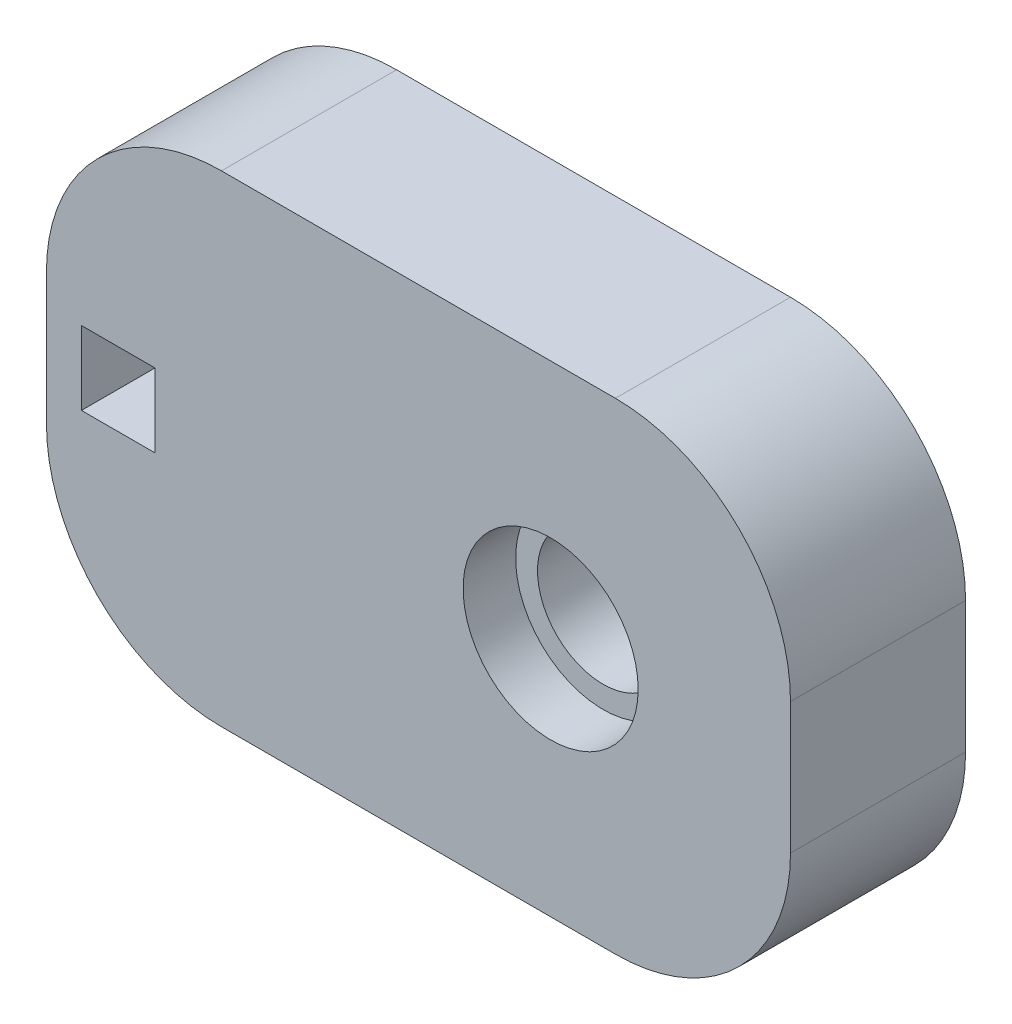
from build123d import *

# Parameters (mm, degrees)
SKETCH1_W           = 42.5
SKETCH1_H           = 27.5
BOSS_EXTRUDE1_DEPTH = 10
SKETCH2_R           = 5
CUT_EXTRUDE1_DEPTH  = 3
SKETCH3_W           = 4.2
SKETCH3_H           = 4.2
CUT_EXTRUDE2_DEPTH  = 5
SKETCH4_R           = 3.75
CUT_EXTRUDE3_DEPTH  = 7.5
FILLET1_R           = 10


with BuildPart() as part:
    # Sketch1 → Boss-Extrude1 (new body)
    with BuildSketch(Plane.XY):
        with Locations((325.175597792, -225.758680099)):
            Rectangle(SKETCH1_W, SKETCH1_H)
    extrude(amount=BOSS_EXTRUDE1_DEPTH)

    # Sketch2 → Cut-Extrude1 (cut)
    with BuildSketch(Plane.XY.offset(10)):
        with Locations((332.725597792, -225.758680099)):
            Circle(SKETCH2_R)
    extrude(amount=-CUT_EXTRUDE1_DEPTH, mode=Mode.SUBTRACT)

    # Sketch3 → Cut-Extrude2 (cut)
    with BuildSketch(Plane.XY.offset(10)):
        with Locations((308.025597792, -225.758680099)):
            Rectangle(SKETCH3_W, SKETCH3_H)
    extrude(amount=-CUT_EXTRUDE2_DEPTH, mode=Mode.SUBTRACT)

    # Sketch4 → Cut-Extrude3 (cut)
    with BuildSketch(Plane.XY.offset(10)):
        with Locations((332.725597792, -225.758680099)):
            Circle(SKETCH4_R)
    extrude(amount=-CUT_EXTRUDE3_DEPTH, mode=Mode.SUBTRACT)

    # Fillet1
    fillet1_edges = [part.edges().sort_by_distance(p)[0] for p in [
        (303.925597792, -212.008680099, 5),
        (303.925597792, -239.508680099, 5),
        (346.425597792, -239.508680099, 5),
        (346.425597792, -212.008680099, 5),
    ]]
    fillet(fillet1_edges, radius=FILLET1_R)


solid = part.part
